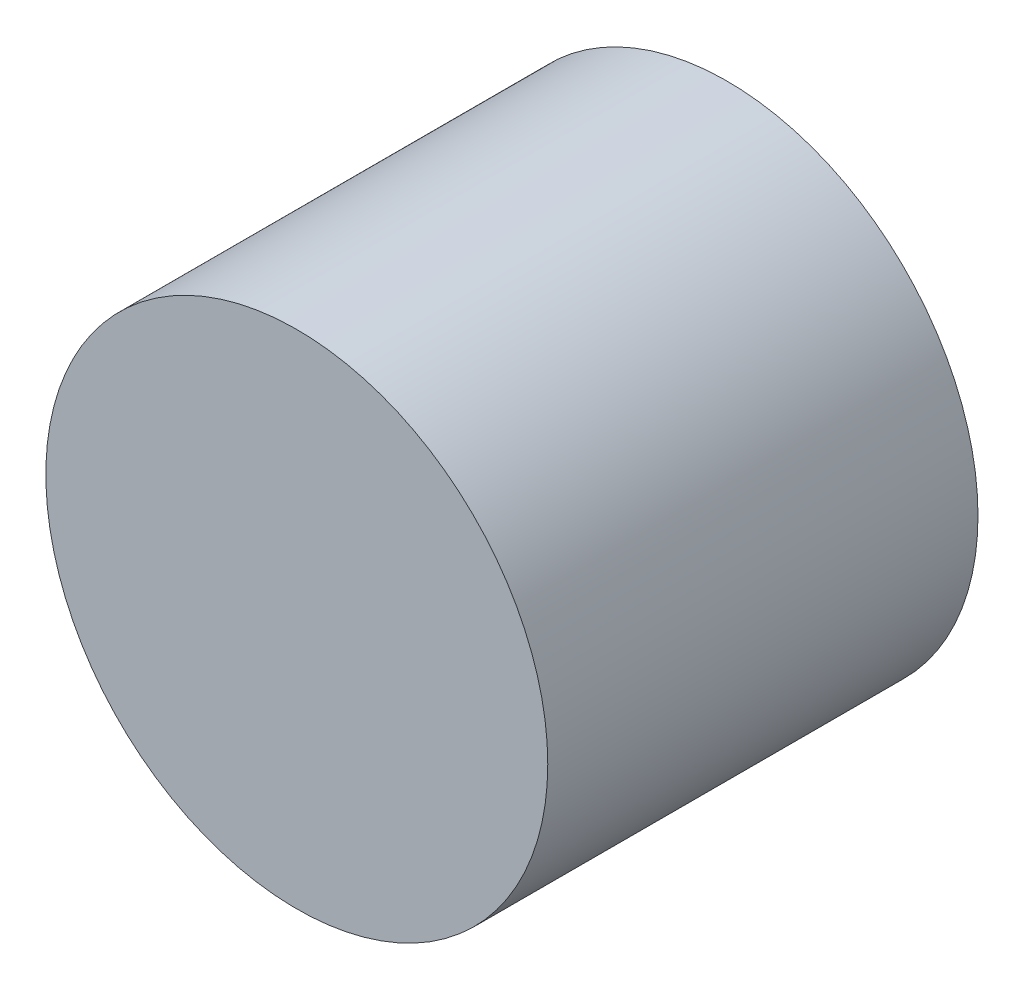
from build123d import *

# Parameters (mm, degrees)
SCHIZZO1_R                   = 1.75
ESTRUSIONE_ESTRUSIONE1_DEPTH = 3


with BuildPart() as part:
    # Schizzo1 → Estrusione-Estrusione1 (new body)
    with BuildSketch(Plane.XY):
        Circle(SCHIZZO1_R)
    extrude(amount=ESTRUSIONE_ESTRUSIONE1_DEPTH)


solid = part.part
